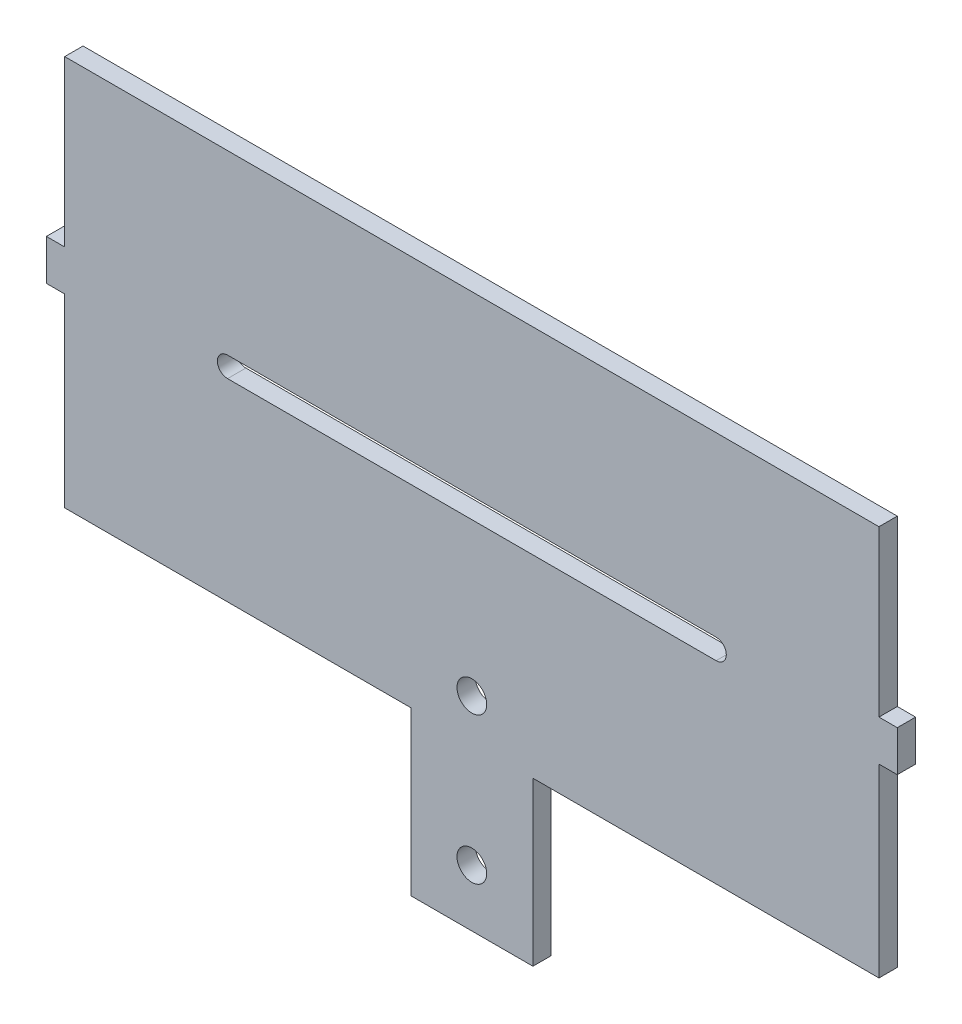
from build123d import *

# Parameters (mm, degrees)
BOSS_EXTRUDE1_DEPTH     = 5.715
CUT_EXTRUDE1_DEPTH      = 6.715
SKETCH4_R               = 4.6355
CUT_EXTRUDE2_DEPTH      = 1
CUT_EXTRUDE2_DEPTH_BACK = 6.715
SKETCH5_W               = 254
SKETCH5_H               = 5.08
CUT_EXTRUDE3_DEPTH      = 6.715
SKETCH6_R               = 4.6355
CUT_EXTRUDE4_DEPTH      = 6.715


with BuildPart() as part:
    # Sketch1 → Boss-Extrude1 (new body)
    with BuildSketch(Plane.XY):
        Polygon((19.05, -63.5), (127, -63.5), (127, -5.715), (132.715, -5.715), (132.715, 6.985), (127, 6.985), (127, 63.5), (-127, 63.5), (-127, 6.985), (-132.715, 6.985), (-132.715, -5.715), (-127, -5.715), (-127, -63.5), (-19.05, -63.5), (-19.05, -114.3), (19.05, -114.3), align=None)
    extrude(amount=BOSS_EXTRUDE1_DEPTH)

    # Sketch2 → Cut-Extrude1 (cut, through all)
    with BuildSketch(Plane.XY.offset(5.715)):
        with BuildLine():
            Line((76.2, -3.175), (-76.2, -3.175))
            ThreePointArc((-76.2, -3.175), (-79.375, 0), (-76.2, 3.175))
            Line((-76.2, 3.175), (76.2, 3.175))
            ThreePointArc((76.2, 3.175), (79.375, 0), (76.2, -3.175))
        make_face()
    extrude(amount=-CUT_EXTRUDE1_DEPTH, mode=Mode.SUBTRACT)

    # Sketch4 → Cut-Extrude2 (cut, two sides)
    with BuildSketch(Plane.XY.offset(5.715)) as cut_extrude2_sk:
        with Locations((0, -50.8)):
            Circle(SKETCH4_R)
    extrude(amount=CUT_EXTRUDE2_DEPTH, mode=Mode.SUBTRACT)
    extrude(cut_extrude2_sk.sketch, amount=-CUT_EXTRUDE2_DEPTH_BACK, mode=Mode.SUBTRACT)

    # Sketch5 → Cut-Extrude3 (cut, through all)
    with BuildSketch(Plane.XY.offset(5.715)):
        with Locations((0, 60.96)):
            Rectangle(SKETCH5_W, SKETCH5_H)
    extrude(amount=-CUT_EXTRUDE3_DEPTH, mode=Mode.SUBTRACT)

    # Sketch6 → Cut-Extrude4 (cut, through all)
    with BuildSketch(Plane.XY.offset(5.715)):
        with Locations((0, -96.52)):
            Circle(SKETCH6_R)
    extrude(amount=-CUT_EXTRUDE4_DEPTH, mode=Mode.SUBTRACT)


solid = part.part
